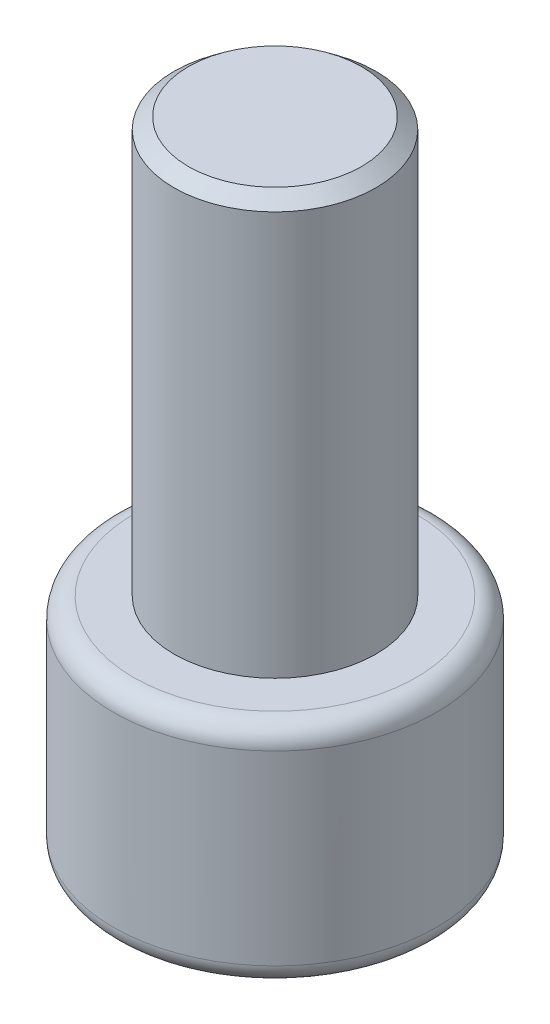
from build123d import *

# Parameters (mm, degrees)
CORTAR_EXTRUIR1_DEPTH = 7
REDONDEO1_R           = 1


with BuildPart() as part:
    # Croquis1 → Revolución2 (revolve)
    with BuildSketch(Plane.XY):
        Polygon((-5, 31.216383588), (-5, 11.216383588), (-8, 11.216383588), (-8, 0), (0, 0), (0, 31.772433039), (-4.288289157, 31.772433039), align=None)
    revolve(axis=Axis((0, 0, 0), (0, 1, 0)))

    # Croquis2 → Cortar-Extruir1 (cut)
    with BuildSketch(Plane.XZ):
        Polygon((0, 5.196152423), (-4.5, 2.598076211), (-4.5, -2.598076211), (0, -5.196152423), (4.5, -2.598076211), (4.5, 2.598076211), align=None)
    extrude(amount=-CORTAR_EXTRUIR1_DEPTH, mode=Mode.SUBTRACT)

    # Redondeo1
    redondeo1_edges = [part.edges().sort_by_distance(p)[0] for p in [
        (8, 11.216383588, 0),
        (8, 0, 0),
    ]]
    fillet(redondeo1_edges, radius=REDONDEO1_R)


solid = part.part
